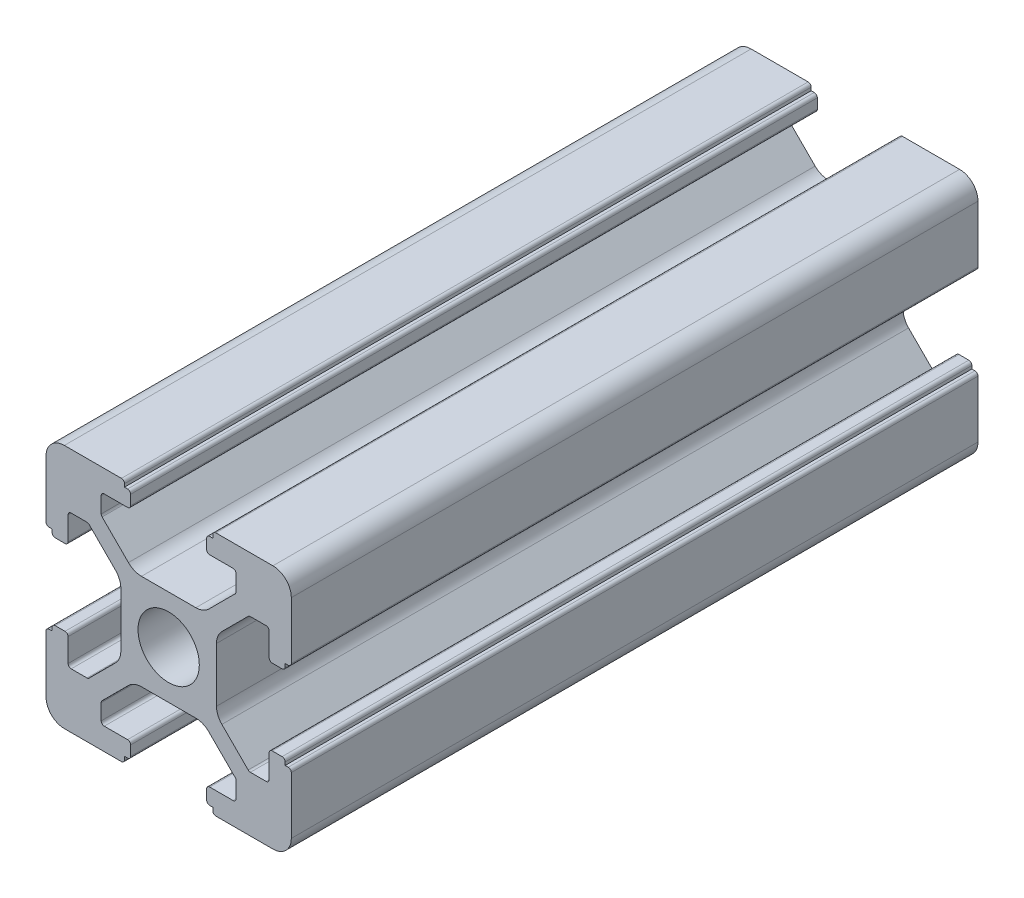
from build123d import *

# Parameters (mm, degrees)
SKETCH_1_R      = 2.5
EXTRUDE_1_DEPTH = 56


with BuildPart() as part:
    # 草图1 → 凸台-拉伸1 (new body)
    with BuildSketch(Plane.XY):
        with BuildLine():
            Line((-8.502261885, -10.002261885), (-3.85, -10.002261885))
            ThreePointArc((-3.85, -10.002261885), (-3.673223305, -9.929038581), (-3.6, -9.752261885))
            Line((-3.6, -9.752261885), (-3.6, -9.502261885))
            Line((-3.6, -9.502261885), (-3.35, -9.502261885))
            ThreePointArc((-3.35, -9.502261885), (-3.173223305, -9.429038581), (-3.1, -9.252261885))
            Line((-3.1, -9.252261885), (-3.1, -8.45))
            ThreePointArc((-3.1, -8.45), (-3.173223305, -8.273223305), (-3.35, -8.2))
            Line((-3.35, -8.2), (-5.25, -8.2))
            ThreePointArc((-5.25, -8.2), (-5.426776695, -8.126776695), (-5.5, -7.95))
            Line((-5.5, -7.95), (-5.5, -6.664213562))
            ThreePointArc((-5.5, -6.664213562), (-5.480969883, -6.568542704), (-5.426776695, -6.487436867))
            Line((-5.426776695, -6.487436867), (-3.278679656, -4.339339828))
            ThreePointArc((-3.278679656, -4.339339828), (-2.792044633, -4.014180701), (-2.218019485, -3.9))
            Line((-2.218019485, -3.9), (2.218019485, -3.9))
            ThreePointArc((2.218019485, -3.9), (2.792044633, -4.014180701), (3.278679656, -4.339339828))
            Line((3.278679656, -4.339339828), (5.426776695, -6.487436867))
            ThreePointArc((5.426776695, -6.487436867), (5.480969883, -6.568542704), (5.5, -6.664213562))
            Line((5.5, -6.664213562), (5.5, -7.95))
            ThreePointArc((5.5, -7.95), (5.426776695, -8.126776695), (5.25, -8.2))
            Line((5.25, -8.2), (3.35, -8.2))
            ThreePointArc((3.35, -8.2), (3.173223305, -8.273223305), (3.1, -8.45))
            Line((3.1, -8.45), (3.1, -9.252261885))
            ThreePointArc((3.1, -9.252261885), (3.173223305, -9.429038581), (3.35, -9.502261885))
            Line((3.35, -9.502261885), (3.6, -9.502261885))
            Line((3.6, -9.502261885), (3.6, -9.752261885))
            ThreePointArc((3.6, -9.752261885), (3.673223305, -9.929038581), (3.85, -10.002261885))
            Line((3.85, -10.002261885), (8.502261885, -10.002261885))
            ThreePointArc((8.502261885, -10.002261885), (9.562922057, -9.562922057), (10.002261885, -8.502261885))
            Line((10.002261885, -8.502261885), (10.002261885, -3.85))
            ThreePointArc((10.002261885, -3.85), (9.929038581, -3.673223305), (9.752261885, -3.6))
            Line((9.752261885, -3.6), (9.502261885, -3.6))
            Line((9.502261885, -3.6), (9.502261885, -3.35))
            ThreePointArc((9.502261885, -3.35), (9.429038581, -3.173223305), (9.252261885, -3.1))
            Line((9.252261885, -3.1), (8.45, -3.1))
            ThreePointArc((8.45, -3.1), (8.273223305, -3.173223305), (8.2, -3.35))
            Line((8.2, -3.35), (8.2, -5.25))
            ThreePointArc((8.2, -5.25), (8.126776695, -5.426776695), (7.95, -5.5))
            Line((7.95, -5.5), (6.664213562, -5.5))
            ThreePointArc((6.664213562, -5.5), (6.568542704, -5.480969883), (6.487436867, -5.426776695))
            Line((6.487436867, -5.426776695), (4.339339828, -3.278679656))
            ThreePointArc((4.339339828, -3.278679656), (4.014180701, -2.792044633), (3.9, -2.218019485))
            Line((3.9, -2.218019485), (3.9, 2.218019485))
            ThreePointArc((3.9, 2.218019485), (4.014180701, 2.792044633), (4.339339828, 3.278679656))
            Line((4.339339828, 3.278679656), (6.487436867, 5.426776695))
            ThreePointArc((6.487436867, 5.426776695), (6.568542704, 5.480969883), (6.664213562, 5.5))
            Line((6.664213562, 5.5), (7.95, 5.5))
            ThreePointArc((7.95, 5.5), (8.126776695, 5.426776695), (8.2, 5.25))
            Line((8.2, 5.25), (8.2, 3.35))
            ThreePointArc((8.2, 3.35), (8.273223305, 3.173223305), (8.45, 3.1))
            Line((8.45, 3.1), (9.252261885, 3.1))
            ThreePointArc((9.252261885, 3.1), (9.429038581, 3.173223305), (9.502261885, 3.35))
            Line((9.502261885, 3.35), (9.502261885, 3.6))
            Line((9.502261885, 3.6), (9.752261885, 3.6))
            ThreePointArc((9.752261885, 3.6), (9.929038581, 3.673223305), (10.002261885, 3.85))
            Line((10.002261885, 3.85), (10.002261885, 8.502261885))
            ThreePointArc((10.002261885, 8.502261885), (9.562922057, 9.562922057), (8.502261885, 10.002261885))
            Line((8.502261885, 10.002261885), (3.85, 10.002261885))
            ThreePointArc((3.85, 10.002261885), (3.673223305, 9.929038581), (3.6, 9.752261885))
            Line((3.6, 9.752261885), (3.6, 9.502261885))
            Line((3.6, 9.502261885), (3.35, 9.502261885))
            ThreePointArc((3.35, 9.502261885), (3.173223305, 9.429038581), (3.1, 9.252261885))
            Line((3.1, 9.252261885), (3.1, 8.45))
            ThreePointArc((3.1, 8.45), (3.173223305, 8.273223305), (3.35, 8.2))
            Line((3.35, 8.2), (5.25, 8.2))
            ThreePointArc((5.25, 8.2), (5.426776695, 8.126776695), (5.5, 7.95))
            Line((5.5, 7.95), (5.5, 6.664213562))
            ThreePointArc((5.5, 6.664213562), (5.480969883, 6.568542704), (5.426776695, 6.487436867))
            Line((5.426776695, 6.487436867), (3.278679656, 4.339339828))
            ThreePointArc((3.278679656, 4.339339828), (2.792044633, 4.014180701), (2.218019485, 3.9))
            Line((2.218019485, 3.9), (-2.218019485, 3.9))
            ThreePointArc((-2.218019485, 3.9), (-2.792044633, 4.014180701), (-3.278679656, 4.339339828))
            Line((-3.278679656, 4.339339828), (-5.426776695, 6.487436867))
            ThreePointArc((-5.426776695, 6.487436867), (-5.480969883, 6.568542704), (-5.5, 6.664213562))
            Line((-5.5, 6.664213562), (-5.5, 7.95))
            ThreePointArc((-5.5, 7.95), (-5.426776695, 8.126776695), (-5.25, 8.2))
            Line((-5.25, 8.2), (-3.35, 8.2))
            ThreePointArc((-3.35, 8.2), (-3.173223305, 8.273223305), (-3.1, 8.45))
            Line((-3.1, 8.45), (-3.1, 9.252261885))
            ThreePointArc((-3.1, 9.252261885), (-3.173223305, 9.429038581), (-3.35, 9.502261885))
            Line((-3.35, 9.502261885), (-3.6, 9.502261885))
            Line((-3.6, 9.502261885), (-3.6, 9.752261885))
            ThreePointArc((-3.6, 9.752261885), (-3.673223305, 9.929038581), (-3.85, 10.002261885))
            Line((-3.85, 10.002261885), (-8.502261885, 10.002261885))
            ThreePointArc((-8.502261885, 10.002261885), (-9.562922057, 9.562922057), (-10.002261885, 8.502261885))
            Line((-10.002261885, 8.502261885), (-10.002261885, 3.85))
            ThreePointArc((-10.002261885, 3.85), (-9.929038581, 3.673223305), (-9.752261885, 3.6))
            Line((-9.752261885, 3.6), (-9.502261885, 3.6))
            Line((-9.502261885, 3.6), (-9.502261885, 3.35))
            ThreePointArc((-9.502261885, 3.35), (-9.429038581, 3.173223305), (-9.252261885, 3.1))
            Line((-9.252261885, 3.1), (-8.45, 3.1))
            ThreePointArc((-8.45, 3.1), (-8.273223305, 3.173223305), (-8.2, 3.35))
            Line((-8.2, 3.35), (-8.2, 5.25))
            ThreePointArc((-8.2, 5.25), (-8.126776695, 5.426776695), (-7.95, 5.5))
            Line((-7.95, 5.5), (-6.664213562, 5.5))
            ThreePointArc((-6.664213562, 5.5), (-6.568542704, 5.480969883), (-6.487436867, 5.426776695))
            Line((-6.487436867, 5.426776695), (-4.339339828, 3.278679656))
            ThreePointArc((-4.339339828, 3.278679656), (-4.014180701, 2.792044633), (-3.9, 2.218019485))
            Line((-3.9, 2.218019485), (-3.9, -2.218019485))
            ThreePointArc((-3.9, -2.218019485), (-4.014180701, -2.792044633), (-4.339339828, -3.278679656))
            Line((-4.339339828, -3.278679656), (-6.487436867, -5.426776695))
            ThreePointArc((-6.487436867, -5.426776695), (-6.568542704, -5.480969883), (-6.664213562, -5.5))
            Line((-6.664213562, -5.5), (-7.95, -5.5))
            ThreePointArc((-7.95, -5.5), (-8.126776695, -5.426776695), (-8.2, -5.25))
            Line((-8.2, -5.25), (-8.2, -3.35))
            ThreePointArc((-8.2, -3.35), (-8.273223305, -3.173223305), (-8.45, -3.1))
            Line((-8.45, -3.1), (-9.252261885, -3.1))
            ThreePointArc((-9.252261885, -3.1), (-9.429038581, -3.173223305), (-9.502261885, -3.35))
            Line((-9.502261885, -3.35), (-9.502261885, -3.6))
            Line((-9.502261885, -3.6), (-9.752261885, -3.6))
            ThreePointArc((-9.752261885, -3.6), (-9.929038581, -3.673223305), (-10.002261885, -3.85))
            Line((-10.002261885, -3.85), (-10.002261885, -8.502261885))
            ThreePointArc((-10.002261885, -8.502261885), (-9.562922057, -9.562922057), (-8.502261885, -10.002261885))
        make_face()
        Circle(SKETCH_1_R, mode=Mode.SUBTRACT)
    extrude(amount=EXTRUDE_1_DEPTH)


solid = part.part
